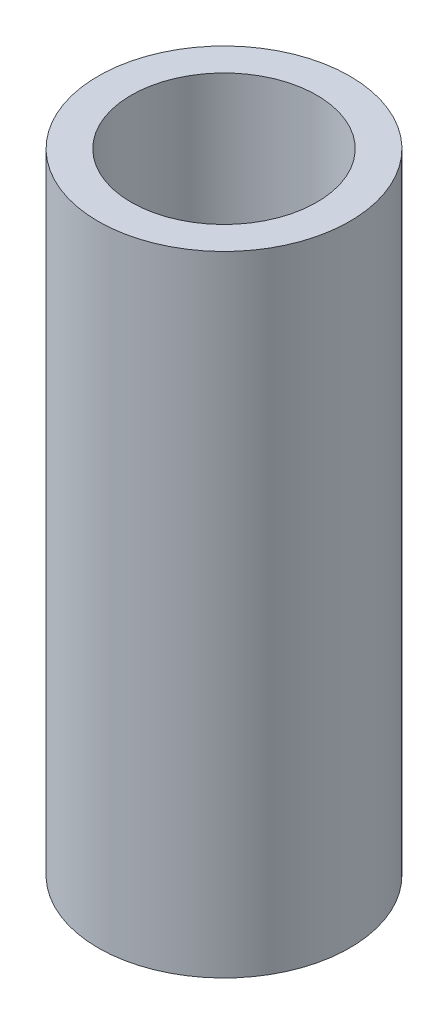
from build123d import *

# Parameters (mm, degrees)
SKETCH1_R           = 4
SKETCH1_R_2         = 2.95
BOSS_EXTRUDE1_DEPTH = 20


with BuildPart() as part:
    # Sketch1 → Boss-Extrude1 (new body)
    with BuildSketch(Plane(origin=(0, 0, 0), x_dir=(1, 0, 0), z_dir=(0, 1, 0))):
        Circle(SKETCH1_R)
        Circle(SKETCH1_R_2, mode=Mode.SUBTRACT)
    extrude(amount=BOSS_EXTRUDE1_DEPTH)


solid = part.part
